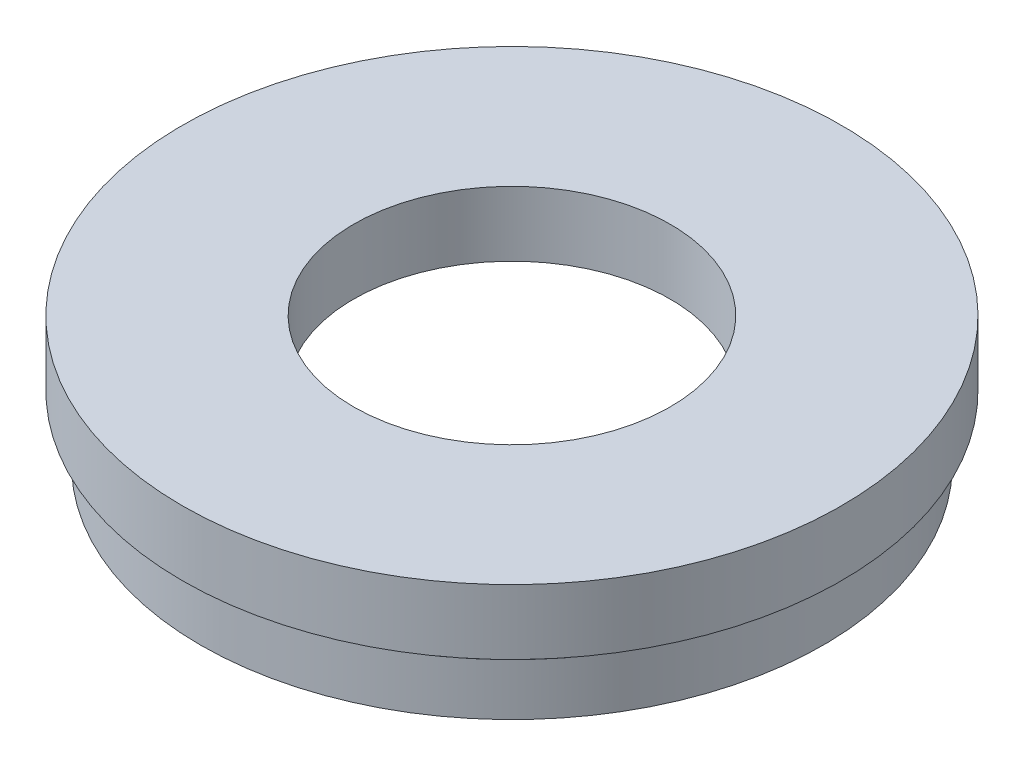
from build123d import *


with BuildPart() as part:
    # 草图1 → 旋转1 (revolve)
    with BuildSketch(Plane.XY, mode=Mode.PRIVATE) as revolve_1_sk:
        Polygon((20.5, 0), (20.5, 4), (21.1, 4), (21.1, 5), (12.2, 5), (12.2, 10), (25.4, 10), (25.4, 5), (23.5, 5), (23.5, 4), (24, 4), (24, 0), align=None)
    revolve(revolve_1_sk.sketch.rotate(Axis((0, 17.419298318, 0), (0, -1, 0)), 90), axis=Axis((0, 17.419298318, 0), (0, -1, 0)))  # turned: the seam where the file's is


solid = part.part
